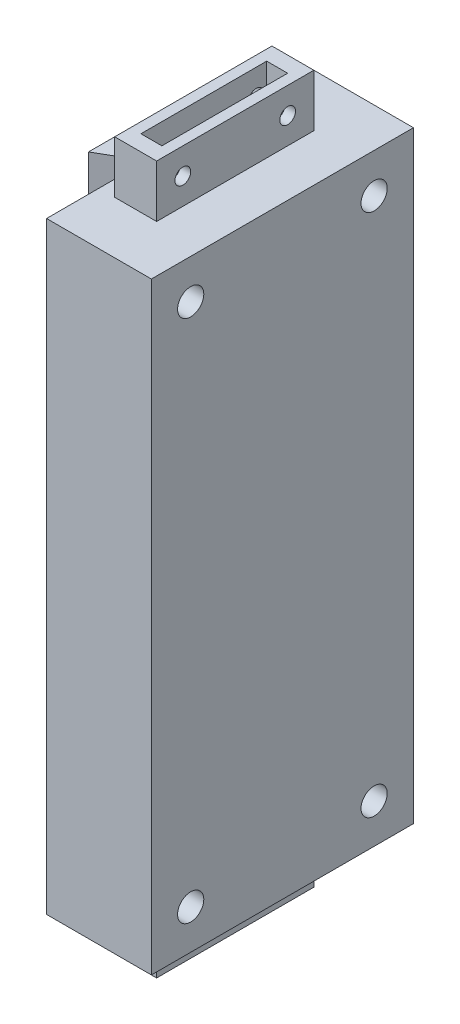
from build123d import *

# Parameters (mm, degrees)
BOSS_EXTRUDE1_DEPTH = 115
SKETCH2_R           = 2.5
CUT_EXTRUDE1_DEPTH  = 10
SKETCH3_W           = 8
SKETCH3_H           = 30
BOSS_EXTRUDE2_DEPTH = 10
SKETCH4_W           = 8
SKETCH4_H           = 30
BOSS_EXTRUDE3_DEPTH = 10
SKETCH5_W           = 4
SKETCH5_H           = 24
CUT_EXTRUDE2_DEPTH  = 10
SKETCH6_W           = 4
SKETCH6_H           = 24
CUT_EXTRUDE3_DEPTH  = 10
SKETCH7_R           = 1.5
CUT_EXTRUDE4_DEPTH  = 32


with BuildPart() as part:
    # Sketch1 → Boss-Extrude1 (new body)
    with BuildSketch(Plane(origin=(0, 0, 0), x_dir=(1, 0, 0), z_dir=(0, 1, 0))):
        Polygon((-27, 10), (-27, -10), (-20, -5.958548116), (-20, -25), (0, -25), (0, 25), (-20, 25), (-20, 5.958548116), align=None)
    extrude(amount=BOSS_EXTRUDE1_DEPTH)

    # Sketch2 → Cut-Extrude1 (cut)
    with BuildSketch(Plane(origin=(0, 0, 0), x_dir=(0, 0, -1), z_dir=(1, 0, 0))):
        with Locations((-17.5, 107.5)):
            Circle(SKETCH2_R)
        with Locations((-17.5, 7.5)):
            Circle(SKETCH2_R)
        with Locations((17.5, 7.5)):
            Circle(SKETCH2_R)
        with Locations((17.5, 107.5)):
            Circle(SKETCH2_R)
    extrude(amount=-CUT_EXTRUDE1_DEPTH, mode=Mode.SUBTRACT)

    # Sketch3 → Boss-Extrude2 (add)
    with BuildSketch(Plane(origin=(0, 115, 0), x_dir=(1, 0, 0), z_dir=(0, 1, 0))):
        with Locations((-13, 0)):
            Rectangle(SKETCH3_W, SKETCH3_H)
    extrude(amount=BOSS_EXTRUDE2_DEPTH)

    # Sketch4 → Boss-Extrude3 (add)
    with BuildSketch(Plane.XZ):
        with Locations((-13, 0)):
            Rectangle(SKETCH4_W, SKETCH4_H)
    extrude(amount=BOSS_EXTRUDE3_DEPTH)

    # Sketch5 → Cut-Extrude2 (cut)
    with BuildSketch(Plane.XZ.offset(10)):
        with Locations((-13, 0)):
            Rectangle(SKETCH5_W, SKETCH5_H)
    extrude(amount=-CUT_EXTRUDE2_DEPTH, mode=Mode.SUBTRACT)

    # Sketch6 → Cut-Extrude3 (cut)
    with BuildSketch(Plane(origin=(0, 125, 0), x_dir=(1, 0, 0), z_dir=(0, 1, 0))):
        with Locations((-13, 0)):
            Rectangle(SKETCH6_W, SKETCH6_H)
    extrude(amount=-CUT_EXTRUDE3_DEPTH, mode=Mode.SUBTRACT)

    # Sketch7 → Cut-Extrude4 (cut)
    with BuildSketch(Plane(origin=(0, 0, 0), x_dir=(0, 0, -1), z_dir=(1, 0, 0))):
        with Locations((-10, 120)):
            Circle(SKETCH7_R)
        with Locations((-10, -5)):
            Circle(SKETCH7_R)
        with Locations((10, -5)):
            Circle(SKETCH7_R)
        with Locations((10, 120)):
            Circle(SKETCH7_R)
    extrude(amount=-CUT_EXTRUDE4_DEPTH, mode=Mode.SUBTRACT)


solid = part.part
